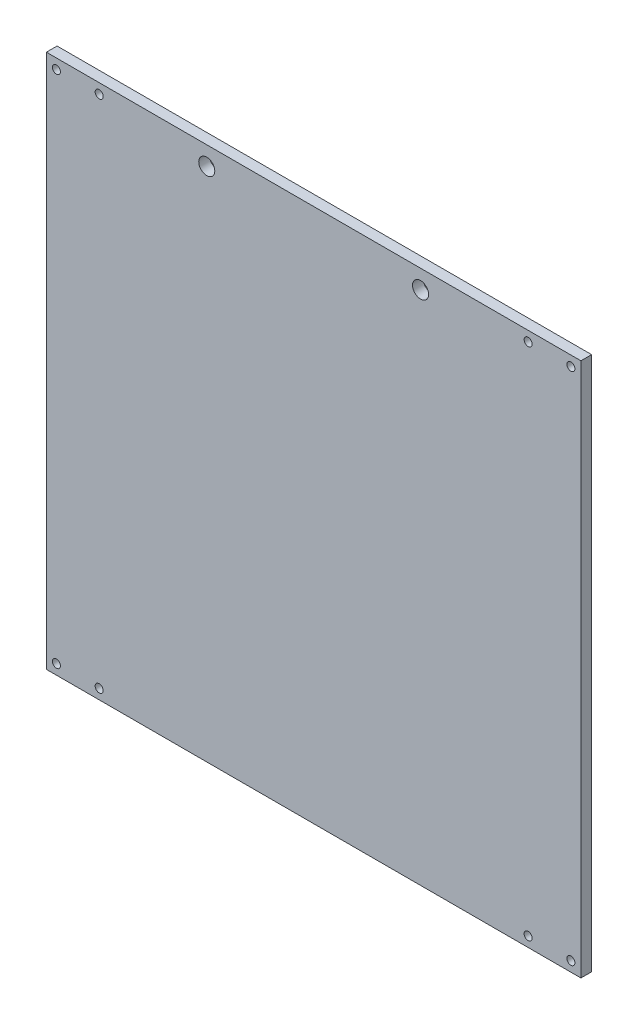
from build123d import *

# Parameters (mm, degrees)
SKETCH1_W                 = 200
SKETCH1_H                 = 200
BOSS_EXTRUDE1_DEPTH       = 4
F_3_0MM_DOWEL_HOLE1_D     = 3
F_3_0MM_DOWEL_HOLE1_DEPTH = 4.001
MIRROR2_COPY_1_D          = 3
MIRROR2_COPY_1_DEPTH      = 4.001
CUT_EXTRUDE1_REACH        = 6
SKETCH6_R                 = 3


with BuildPart() as part:
    # Sketch1 → Boss-Extrude1 (new body)
    with BuildSketch(Plane.XY):
        Rectangle(SKETCH1_W, SKETCH1_H)
    extrude(amount=BOSS_EXTRUDE1_DEPTH)

    # Ø3.0mm Dowel Hole1
    with Locations(Plane.XY.offset(4)):
        with Locations((-80.25, 96.25), (-96.25, 96.25)):
            f_3_0mm_dowel_hole1 = Hole(F_3_0MM_DOWEL_HOLE1_D / 2, depth=F_3_0MM_DOWEL_HOLE1_DEPTH)

    # Mirror1: Ø3.0mm Dowel Hole1 across plane
    add(f_3_0mm_dowel_hole1.mirror(Plane.ZY), mode=Mode.SUBTRACT)

    # Mirror2: Ø3.0mm Dowel Hole1 across plane
    add(f_3_0mm_dowel_hole1.mirror(Plane.ZX), mode=Mode.SUBTRACT)

    # Mirror2 copy 1
    with Locations(Plane(origin=(0, 0, 4), x_dir=(-1, 0, 0), z_dir=(0, 0, 1))):
        with Locations((-80.25, 96.25), (-96.25, 96.25)):
            Hole(MIRROR2_COPY_1_D / 2, depth=MIRROR2_COPY_1_DEPTH)

    # Sketch6 → Cut-Extrude1 (cut, up to next)
    with BuildSketch(Plane(origin=(0, 0, 0), x_dir=(-1, 0, 0), z_dir=(0, 0, -1)), mode=Mode.PRIVATE) as cut_extrude1_sk1:
        with Locations((-40, 93)):
            Circle(SKETCH6_R)
    cut_extrude1_tool1 = extrude(cut_extrude1_sk1.sketch, amount=-CUT_EXTRUDE1_REACH, mode=Mode.PRIVATE) & part.part
    add(cut_extrude1_tool1.solids().sort_by_distance((40, 93, 0))[0], mode=Mode.SUBTRACT)
    # Sketch6 → Cut-Extrude1 (cut, up to next)
    with BuildSketch(Plane(origin=(0, 0, 0), x_dir=(-1, 0, 0), z_dir=(0, 0, -1)), mode=Mode.PRIVATE) as cut_extrude1_sk2:
        with Locations((40, 93)):
            Circle(SKETCH6_R)
    cut_extrude1_tool2 = extrude(cut_extrude1_sk2.sketch, amount=-CUT_EXTRUDE1_REACH, mode=Mode.PRIVATE) & part.part
    add(cut_extrude1_tool2.solids().sort_by_distance((-40, 93, 0))[0], mode=Mode.SUBTRACT)


solid = part.part
